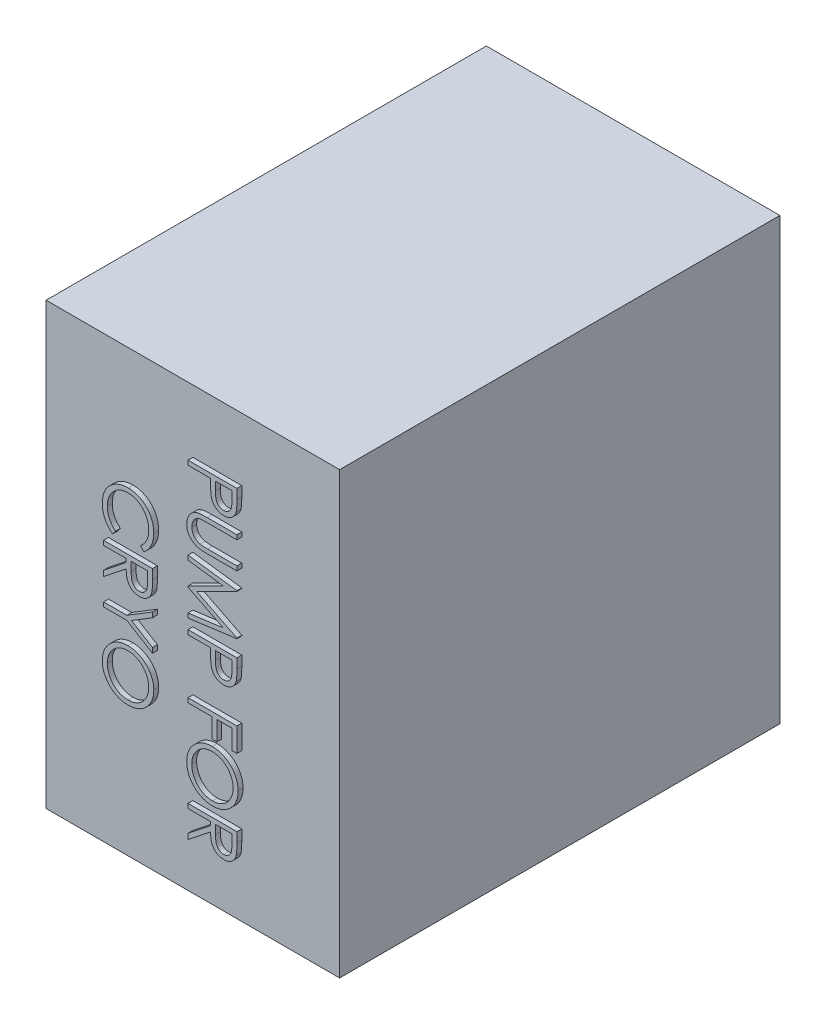
from build123d import *

# Parameters (mm, degrees)
SKETCH1_W           = 300
SKETCH1_H           = 450
BOSS_EXTRUDE1_DEPTH = 450
BOSS_EXTRUDE2_DEPTH = 5


with BuildPart() as part:
    # Sketch1 → Boss-Extrude1 (new body)
    with BuildSketch(Plane.XY):
        with Locations((-150, -225)):
            Rectangle(SKETCH1_W, SKETCH1_H)
    extrude(amount=BOSS_EXTRUDE1_DEPTH)

    # Sketch2 → Boss-Extrude2 (add)
    with BuildSketch(Plane.XY.offset(450)):
        with BuildLine():
            Line((-100, -64.102564103), (-100, -73.908253205))
            add(Edge.make_bspline(
                [(-100, -73.908253205), (-100.000741375, -74.582694722), (-100.002161882, -75.874954619), (-100.04522968, -77.728026843), (-100.102753852, -79.411023009), (-100.182495184, -80.920314165), (-100.276732187, -82.260544138), (-100.408904178, -83.425648417), (-100.5469084, -84.424784936), (-100.687214208, -85.0234485), (-100.751201923, -85.296474359)],
                knots=[0, 0, 0, 0, 0.002023262, 0.00387666, 0.005560425, 0.007074966, 0.008410857, 0.009589944, 0.010592848, 0.011433717, 0.011433717, 0.011433717, 0.011433717], degree=3))
            add(Edge.make_bspline(
                [(-100.751201923, -85.296474359), (-100.845800362, -85.642097086), (-101.032768147, -86.325198373), (-101.407262122, -87.309487184), (-101.851247723, -88.246014513), (-102.357471585, -89.137731916), (-102.946645825, -89.97464631), (-103.600133174, -90.76747075), (-104.317574111, -91.520752651), (-105.112876751, -92.208903257), (-105.956718523, -92.842434238), (-106.867892244, -93.385907714), (-107.826566564, -93.845614526), (-108.842559481, -94.221054979), (-109.909696057, -94.506534547), (-111.031091598, -94.717455866), (-112.202892896, -94.852405942), (-113.003765212, -94.86525428), (-113.411458333, -94.871794872)],
                knots=[0, 0, 0, 0, 0.001074519, 0.002123719, 0.003154202, 0.004181614, 0.005195808, 0.006220482, 0.007261811, 0.008312396, 0.009372109, 0.010423362, 0.011489587, 0.012557551, 0.01366793, 0.014799431, 0.015978517, 0.017201129, 0.017201129, 0.017201129, 0.017201129], degree=3))
            add(Edge.make_bspline(
                [(-113.411458333, -94.871794872), (-113.82256943, -94.865774519), (-114.626936058, -94.853995291), (-115.803690175, -94.712619786), (-116.928238606, -94.522188477), (-117.998087898, -94.229373444), (-119.006884619, -93.845863828), (-119.970045076, -93.395977359), (-120.871183246, -92.853355497), (-121.71357064, -92.229857929), (-122.497997959, -91.536263724), (-123.218780737, -90.775507464), (-123.871699857, -89.950660429), (-124.458219053, -89.064344028), (-124.964737331, -88.107917616), (-125.418413116, -87.09588685), (-125.799428268, -86.019455187), (-125.999857717, -85.27456213), (-126.101762821, -84.895833333)],
                knots=[0, 0, 0, 0, 0.001232622, 0.002411709, 0.003551249, 0.004651965, 0.005732814, 0.006785688, 0.007836942, 0.008882645, 0.009925708, 0.010974286, 0.012022337, 0.013077971, 0.014157938, 0.015265423, 0.016402716, 0.017579034, 0.017579034, 0.017579034, 0.017579034], degree=3))
            add(Edge.make_bspline(
                [(-126.101762821, -84.895833333), (-126.168376836, -84.582585705), (-126.314365324, -83.896085314), (-126.477343279, -82.765474997), (-126.61645186, -81.449112341), (-126.720753825, -79.948794057), (-126.810044803, -78.265866843), (-126.881017573, -76.39942031), (-126.920015485, -74.345790636), (-126.922026811, -72.913344292), (-126.923076923, -72.165464744)],
                knots=[0, 0, 0, 0, 0.000960547, 0.002105094, 0.003424665, 0.004931103, 0.006616208, 0.008480508, 0.010534184, 0.012777796, 0.012777796, 0.012777796, 0.012777796], degree=3))
            Line((-126.923076923, -72.165464744), (-126.923076923, -68.58974359))
            Line((-126.923076923, -68.58974359), (-150, -68.58974359))
            Line((-150, -68.58974359), (-150, -64.102564103))
            Line((-150, -64.102564103), (-100, -64.102564103))
        make_face()
        with BuildLine():
            Line((-105.128205128, -68.58974359), (-121.794871795, -68.58974359))
            Line((-121.794871795, -68.58974359), (-121.905048077, -77.34375))
            add(Edge.make_bspline(
                [(-121.905048077, -77.34375), (-121.90531537, -77.771181692), (-121.905831375, -78.59632976), (-121.848118443, -79.791548756), (-121.784457215, -80.897591588), (-121.684760991, -81.916860184), (-121.553401851, -82.841565239), (-121.410419938, -83.683584272), (-121.216707899, -84.430590566), (-120.946607266, -85.30594516), (-120.494923622, -86.278046537), (-119.822399654, -87.328568408), (-118.988684457, -88.233281863), (-118.038418974, -89.010951), (-116.977443965, -89.613642521), (-115.851169479, -90.066943386), (-114.658886826, -90.330988536), (-113.843404018, -90.366618241), (-113.431490385, -90.384615385)],
                knots=[0, 0, 0, 0, 0.00128209, 0.002475049, 0.003589036, 0.004605601, 0.005546148, 0.006390945, 0.007165878, 0.007859591, 0.009136978, 0.010367687, 0.011587176, 0.012812002, 0.01403695, 0.01523289, 0.016443131, 0.017678396, 0.017678396, 0.017678396, 0.017678396], degree=3))
            add(Edge.make_bspline(
                [(-113.431490385, -90.384615385), (-113.029542859, -90.366522138), (-112.230520924, -90.330555002), (-111.058934898, -90.064860623), (-109.944609761, -89.614527409), (-108.896696682, -89.006867071), (-107.95032017, -88.251527291), (-107.135420641, -87.366863135), (-106.471420622, -86.37093885), (-106.045803633, -85.444036191), (-105.785501602, -84.621235176), (-105.603452769, -83.906475179), (-105.458080533, -83.099471151), (-105.340375336, -82.199929713), (-105.239610992, -81.21483262), (-105.171240074, -80.135713674), (-105.131219215, -78.966661676), (-105.129234148, -78.155082085), (-105.128205128, -77.734375)],
                knots=[0, 0, 0, 0, 0.001205299, 0.002395985, 0.00358262, 0.004798897, 0.00601744, 0.007201239, 0.008392978, 0.009594108, 0.010246612, 0.010980247, 0.011805339, 0.012704832, 0.013701464, 0.01477547, 0.015948029, 0.017210088, 0.017210088, 0.017210088, 0.017210088], degree=3))
            Line((-105.128205128, -77.734375), (-105.128205128, -68.58974359))
        make_face(mode=Mode.SUBTRACT)
        with BuildLine():
            Line((-100, -105.128205128), (-100, -109.615384615))
            Line((-100, -109.615384615), (-129.957932692, -109.615384615))
            add(Edge.make_bspline(
                [(-129.957932692, -109.615384615), (-130.381943203, -109.614716844), (-131.186576217, -109.613449634), (-132.331837653, -109.621914118), (-133.350015639, -109.645619381), (-134.24503489, -109.660564517), (-135.012788425, -109.693812139), (-135.657435721, -109.720927095), (-136.175924327, -109.755792191), (-136.478508985, -109.797693869), (-136.608573718, -109.815705128)],
                knots=[0, 0, 0, 0, 0.001272035, 0.002413906, 0.003435737, 0.004327388, 0.005099208, 0.005740937, 0.006263309, 0.006657131, 0.006657131, 0.006657131, 0.006657131], degree=3))
            add(Edge.make_bspline(
                [(-136.608573718, -109.815705128), (-137.077853835, -109.889597031), (-137.989971814, -110.033217292), (-139.288105566, -110.400576311), (-140.462049998, -110.9094937), (-141.535217976, -111.529128951), (-142.491654872, -112.325994653), (-143.379616216, -113.274423282), (-144.146751983, -114.434228671), (-144.85251309, -115.72302087), (-145.41894825, -117.112989734), (-145.847479077, -118.533104043), (-146.108592437, -119.962301318), (-146.138830514, -120.919102122), (-146.153846154, -121.394230769)],
                knots=[0, 0, 0, 0, 0.001424425, 0.002768589, 0.004033784, 0.005255124, 0.006472184, 0.007755057, 0.009138574, 0.010630995, 0.01215807, 0.013631652, 0.015075801, 0.016500332, 0.016500332, 0.016500332, 0.016500332], degree=3))
            add(Edge.make_bspline(
                [(-146.153846154, -121.394230769), (-146.138506283, -121.802142086), (-146.107915142, -122.615608732), (-145.918453499, -123.824261007), (-145.577065053, -125.001447487), (-145.136314149, -126.152726129), (-144.554883314, -127.232617266), (-143.878583124, -128.240348071), (-143.096878169, -129.149367994), (-142.219448029, -129.969133937), (-141.238481753, -130.686877446), (-140.156934972, -131.292467329), (-138.978363059, -131.80286353), (-138.147300372, -132.052990737), (-137.720352564, -132.181490385)],
                knots=[0, 0, 0, 0, 0.001223965, 0.00244086, 0.003658457, 0.004895345, 0.00613203, 0.007329353, 0.008529815, 0.009720417, 0.010924424, 0.012166775, 0.01343197, 0.01476865, 0.01476865, 0.01476865, 0.01476865], degree=3))
            add(Edge.make_bspline(
                [(-137.720352564, -132.181490385), (-137.543944359, -132.224349317), (-137.150835787, -132.319856292), (-136.486245922, -132.409099792), (-135.702112151, -132.502050155), (-134.792800539, -132.566544012), (-133.761358073, -132.629418589), (-132.602411538, -132.667033915), (-131.32016924, -132.684420099), (-130.425352644, -132.689601247), (-129.957932692, -132.692307692)],
                knots=[0, 0, 0, 0, 0.000544286, 0.001212889, 0.002009273, 0.002913438, 0.003946837, 0.005109387, 0.006391594, 0.007793874, 0.007793874, 0.007793874, 0.007793874], degree=3))
            Line((-129.957932692, -132.692307692), (-100, -132.692307692))
            Line((-100, -132.692307692), (-100, -137.179487179))
            Line((-100, -137.179487179), (-130.198317308, -137.179487179))
            add(Edge.make_bspline(
                [(-130.198317308, -137.179487179), (-130.74258572, -137.175896994), (-131.804758618, -137.16889053), (-133.361125254, -137.106896573), (-134.837883804, -137.010907692), (-136.233150012, -136.865793325), (-137.548585435, -136.705592285), (-138.782268237, -136.476377019), (-139.942470557, -136.236758088), (-141.027205972, -135.933667699), (-142.050826631, -135.56804074), (-143.040331391, -135.139960867), (-143.987631414, -134.616144321), (-144.906408203, -134.018398024), (-145.797920455, -133.354736354), (-146.641231847, -132.589785227), (-147.463990341, -131.76314859), (-148.239046249, -130.857413643), (-148.954892577, -129.888766889), (-149.570663595, -128.855487692), (-150.111345813, -127.77838221), (-150.538432516, -126.645913735), (-150.868999438, -125.465458545), (-151.112273458, -124.237077647), (-151.251058756, -122.956593758), (-151.271632859, -122.085659644), (-151.282051282, -121.64463141)],
                knots=[0, 0, 0, 0, 0.001632735, 0.003186382, 0.004672133, 0.006071405, 0.007394506, 0.008646029, 0.009834564, 0.010947606, 0.012021565, 0.013093467, 0.014178207, 0.015264473, 0.01638026, 0.017508164, 0.018676781, 0.019877243, 0.021081251, 0.022285384, 0.023481366, 0.024692353, 0.025909949, 0.027155324, 0.028445021, 0.029768085, 0.029768085, 0.029768085, 0.029768085], degree=3))
            add(Edge.make_bspline(
                [(-151.282051282, -121.64463141), (-151.27084035, -121.16364423), (-151.248844541, -120.219949103), (-151.122805253, -118.829405285), (-150.88539962, -117.496345338), (-150.58311471, -116.206689952), (-150.166204177, -114.977997136), (-149.679088108, -113.793805073), (-149.080841532, -112.674395343), (-148.415221632, -111.601607791), (-147.666298229, -110.604111275), (-146.85001003, -109.688434087), (-145.97943321, -108.853064507), (-145.045142271, -108.112083131), (-144.054403599, -107.453213351), (-143.004414459, -106.885638874), (-141.895581371, -106.398306815), (-141.124821365, -106.146784429), (-140.735176282, -106.01963141)],
                knots=[0, 0, 0, 0, 0.001443177, 0.002831508, 0.004183412, 0.005502526, 0.006801138, 0.008071634, 0.009339562, 0.010604043, 0.011856046, 0.013076276, 0.014280617, 0.015471008, 0.016648861, 0.017845514, 0.019047604, 0.020276599, 0.020276599, 0.020276599, 0.020276599], degree=3))
            add(Edge.make_bspline(
                [(-140.735176282, -106.01963141), (-140.468996647, -105.945672008), (-139.891647091, -105.785252417), (-138.936125826, -105.61346245), (-137.835912716, -105.469046998), (-136.590932454, -105.333253309), (-135.200220074, -105.253125339), (-133.664378419, -105.182876214), (-131.981550395, -105.127710232), (-130.809343029, -105.128035552), (-130.198317308, -105.128205128)],
                knots=[0, 0, 0, 0, 0.000828429, 0.001796881, 0.00290884, 0.004157634, 0.005552777, 0.007086832, 0.008770269, 0.010603229, 0.010603229, 0.010603229, 0.010603229], degree=3))
            Line((-130.198317308, -105.128205128), (-100, -105.128205128))
        make_face()
        Polygon((-150, -148.076923077), (-100, -154.677483974), (-100, -155.318509615), (-141.025641026, -175.961538462), (-100, -196.554487179), (-100, -197.205528846), (-150, -203.846153846), (-150, -199.338942308), (-114.022435897, -194.551282051), (-150, -176.502403846), (-150, -175.490785256), (-113.942307692, -157.371794872), (-150, -152.594150641), align=None)
        with BuildLine():
            Line((-100, -214.102564103), (-100, -223.908253205))
            add(Edge.make_bspline(
                [(-100, -223.908253205), (-100.000741375, -224.582694722), (-100.002161882, -225.874954619), (-100.04522968, -227.728026843), (-100.102753852, -229.411023009), (-100.182495184, -230.920314165), (-100.276732187, -232.260544138), (-100.408904178, -233.425648417), (-100.5469084, -234.424784936), (-100.687214208, -235.0234485), (-100.751201923, -235.296474359)],
                knots=[0, 0, 0, 0, 0.002023262, 0.00387666, 0.005560425, 0.007074966, 0.008410857, 0.009589944, 0.010592848, 0.011433717, 0.011433717, 0.011433717, 0.011433717], degree=3))
            add(Edge.make_bspline(
                [(-100.751201923, -235.296474359), (-100.845800362, -235.642097086), (-101.032768147, -236.325198373), (-101.407262122, -237.309487184), (-101.851247723, -238.246014513), (-102.357471585, -239.137731916), (-102.946645825, -239.97464631), (-103.600133174, -240.76747075), (-104.317574111, -241.520752651), (-105.112876751, -242.208903257), (-105.956718523, -242.842434238), (-106.867892244, -243.385907714), (-107.826566564, -243.845614526), (-108.842559481, -244.221054979), (-109.909696057, -244.506534547), (-111.031091598, -244.717455866), (-112.202892896, -244.852405942), (-113.003765212, -244.86525428), (-113.411458333, -244.871794872)],
                knots=[0, 0, 0, 0, 0.001074519, 0.002123719, 0.003154202, 0.004181614, 0.005195808, 0.006220482, 0.007261811, 0.008312396, 0.009372109, 0.010423362, 0.011489587, 0.012557551, 0.01366793, 0.014799431, 0.015978517, 0.017201129, 0.017201129, 0.017201129, 0.017201129], degree=3))
            add(Edge.make_bspline(
                [(-113.411458333, -244.871794872), (-113.82256943, -244.865774519), (-114.626936058, -244.853995291), (-115.803690175, -244.712619786), (-116.928238606, -244.522188477), (-117.998087898, -244.229373444), (-119.006884619, -243.845863828), (-119.970045076, -243.395977359), (-120.871183246, -242.853355497), (-121.71357064, -242.229857929), (-122.497997959, -241.536263724), (-123.218780737, -240.775507464), (-123.871699857, -239.950660429), (-124.458219053, -239.064344028), (-124.964737331, -238.107917616), (-125.418413116, -237.09588685), (-125.799428268, -236.019455187), (-125.999857717, -235.27456213), (-126.101762821, -234.895833333)],
                knots=[0, 0, 0, 0, 0.001232622, 0.002411709, 0.003551249, 0.004651965, 0.005732814, 0.006785688, 0.007836942, 0.008882645, 0.009925708, 0.010974286, 0.012022337, 0.013077971, 0.014157938, 0.015265423, 0.016402716, 0.017579034, 0.017579034, 0.017579034, 0.017579034], degree=3))
            add(Edge.make_bspline(
                [(-126.101762821, -234.895833333), (-126.168376836, -234.582585705), (-126.314365324, -233.896085314), (-126.477343279, -232.765474997), (-126.61645186, -231.449112341), (-126.720753825, -229.948794057), (-126.810044803, -228.265866843), (-126.881017573, -226.39942031), (-126.920015485, -224.345790636), (-126.922026811, -222.913344292), (-126.923076923, -222.165464744)],
                knots=[0, 0, 0, 0, 0.000960547, 0.002105094, 0.003424665, 0.004931103, 0.006616208, 0.008480508, 0.010534184, 0.012777796, 0.012777796, 0.012777796, 0.012777796], degree=3))
            Line((-126.923076923, -222.165464744), (-126.923076923, -218.58974359))
            Line((-126.923076923, -218.58974359), (-150, -218.58974359))
            Line((-150, -218.58974359), (-150, -214.102564103))
            Line((-150, -214.102564103), (-100, -214.102564103))
        make_face()
        with BuildLine():
            Line((-105.128205128, -218.58974359), (-121.794871795, -218.58974359))
            Line((-121.794871795, -218.58974359), (-121.905048077, -227.34375))
            add(Edge.make_bspline(
                [(-121.905048077, -227.34375), (-121.90531537, -227.771181692), (-121.905831375, -228.59632976), (-121.848118443, -229.791548756), (-121.784457215, -230.897591588), (-121.684760991, -231.916860184), (-121.553401851, -232.841565239), (-121.410419938, -233.683584272), (-121.216707899, -234.430590566), (-120.946607266, -235.30594516), (-120.494923622, -236.278046537), (-119.822399654, -237.328568408), (-118.988684457, -238.233281863), (-118.038418974, -239.010951), (-116.977443965, -239.613642521), (-115.851169479, -240.066943386), (-114.658886826, -240.330988536), (-113.843404018, -240.366618241), (-113.431490385, -240.384615385)],
                knots=[0, 0, 0, 0, 0.00128209, 0.002475049, 0.003589036, 0.004605601, 0.005546148, 0.006390945, 0.007165878, 0.007859591, 0.009136978, 0.010367687, 0.011587176, 0.012812002, 0.01403695, 0.01523289, 0.016443131, 0.017678396, 0.017678396, 0.017678396, 0.017678396], degree=3))
            add(Edge.make_bspline(
                [(-113.431490385, -240.384615385), (-113.029542859, -240.366522138), (-112.230520924, -240.330555002), (-111.058934898, -240.064860623), (-109.944609761, -239.614527409), (-108.896696682, -239.006867071), (-107.95032017, -238.251527291), (-107.135420641, -237.366863135), (-106.471420622, -236.37093885), (-106.045803633, -235.444036191), (-105.785501602, -234.621235176), (-105.603452769, -233.906475179), (-105.458080533, -233.099471151), (-105.340375336, -232.199929713), (-105.239610992, -231.21483262), (-105.171240074, -230.135713674), (-105.131219215, -228.966661676), (-105.129234148, -228.155082085), (-105.128205128, -227.734375)],
                knots=[0, 0, 0, 0, 0.001205299, 0.002395985, 0.00358262, 0.004798897, 0.00601744, 0.007201239, 0.008392978, 0.009594108, 0.010246612, 0.010980247, 0.011805339, 0.012704832, 0.013701464, 0.01477547, 0.015948029, 0.017210088, 0.017210088, 0.017210088, 0.017210088], degree=3))
            Line((-105.128205128, -227.734375), (-105.128205128, -218.58974359))
        make_face(mode=Mode.SUBTRACT)
        Polygon((-100, -274.358974359), (-100, -298.717948718), (-105.128205128, -298.717948718), (-105.128205128, -278.846153846), (-120.512820513, -278.846153846), (-120.512820513, -298.717948718), (-125.641025641, -298.717948718), (-125.641025641, -278.846153846), (-150, -278.846153846), (-150, -274.358974359), align=None)
        with BuildLine():
            add(Edge.make_bspline(
                [(-98.717948718, -331.08974359), (-98.741398637, -332.015573488), (-98.787456212, -333.833979793), (-99.140011798, -336.506480979), (-99.749957065, -339.057829786), (-100.562244803, -341.508867143), (-101.646028776, -343.830064723), (-102.955254722, -346.039681527), (-104.508542919, -348.131470126), (-106.279829906, -350.086256754), (-108.214087517, -351.868505037), (-110.284239677, -353.425643084), (-112.461938884, -354.742191539), (-114.754762956, -355.821273995), (-117.15262036, -356.668589888), (-119.669144872, -357.253095055), (-122.287801283, -357.626511573), (-124.073900808, -357.670163557), (-124.979967949, -357.692307692)],
                knots=[0, 0, 0, 0, 0.002777041, 0.005454338, 0.008068425, 0.01063716, 0.01318702, 0.015737884, 0.018330081, 0.020989388, 0.023640628, 0.026208738, 0.028747558, 0.031261122, 0.033798499, 0.036361545, 0.039000478, 0.041717481, 0.041717481, 0.041717481, 0.041717481], degree=3))
            add(Edge.make_bspline(
                [(-124.979967949, -357.692307692), (-125.879360815, -357.67016684), (-127.65216835, -357.626524655), (-130.254206432, -357.252670054), (-132.755542924, -356.666424838), (-135.151759294, -355.829133917), (-137.446284297, -354.755235379), (-139.627986339, -353.429788976), (-141.71247244, -351.882960188), (-143.65611999, -350.106872088), (-145.441869477, -348.173075748), (-147.001428456, -346.097085909), (-148.334186754, -343.92152988), (-149.405867874, -341.630091865), (-150.259180439, -339.248317597), (-150.841516307, -336.754378207), (-151.217003142, -334.159401877), (-151.260130639, -332.389819632), (-151.282051282, -331.490384615)],
                knots=[0, 0, 0, 0, 0.00269699, 0.005316081, 0.007869381, 0.010393996, 0.012916623, 0.015455444, 0.018039598, 0.020691481, 0.023342722, 0.025924856, 0.028468867, 0.030982431, 0.033500919, 0.036044476, 0.038653646, 0.041350637, 0.041350637, 0.041350637, 0.041350637], degree=3))
            add(Edge.make_bspline(
                [(-151.282051282, -331.490384615), (-151.259920154, -330.584321144), (-151.216293811, -328.798228853), (-150.84223115, -326.176296608), (-150.257511571, -323.657949966), (-149.421091115, -321.25094288), (-148.344185353, -318.95448547), (-147.020828098, -316.768799838), (-145.461433324, -314.691259538), (-143.687709859, -312.743005951), (-141.752984156, -310.962565541), (-139.690639895, -309.396565391), (-137.520291153, -308.08083757), (-135.250884518, -307.003477198), (-132.888286014, -306.151326164), (-130.417634013, -305.569774909), (-127.852772934, -305.193561631), (-126.106447325, -305.150204675), (-125.220352564, -305.128205128)],
                knots=[0, 0, 0, 0, 0.002717003, 0.005355936, 0.007928729, 0.010462803, 0.01298543, 0.015524251, 0.018114396, 0.020766279, 0.023417519, 0.025991657, 0.028521909, 0.031017367, 0.033516982, 0.03604106, 0.038620474, 0.041277441, 0.041277441, 0.041277441, 0.041277441], degree=3))
            add(Edge.make_bspline(
                [(-125.220352564, -305.128205128), (-124.62559743, -305.135835775), (-123.443590263, -305.151000804), (-121.688393113, -305.333842313), (-119.96123382, -305.598623271), (-118.267918257, -305.980080845), (-116.608169911, -306.472128756), (-114.985383059, -307.078494334), (-113.386190706, -307.773389519), (-111.841028318, -308.600758224), (-110.347470654, -309.503442243), (-108.924193409, -310.48772847), (-107.596620159, -311.560479805), (-106.34341893, -312.70637225), (-105.185979018, -313.941267523), (-104.099065565, -315.246580488), (-103.093929901, -316.629141135), (-102.191682641, -318.091136019), (-101.362957572, -319.595291025), (-100.671040337, -321.15251887), (-100.059478292, -322.729963614), (-99.573467819, -324.341520008), (-99.186697788, -325.983460256), (-98.923897327, -327.657836963), (-98.740649548, -329.362925542), (-98.725548218, -330.511661036), (-98.717948718, -331.08974359)],
                knots=[0, 0, 0, 0, 0.001783556, 0.003544611, 0.005288464, 0.007023435, 0.008747414, 0.010477724, 0.012217776, 0.013974126, 0.015731389, 0.01745126, 0.019160982, 0.02084808, 0.022541499, 0.024234297, 0.025941258, 0.027664393, 0.02938543, 0.031088891, 0.032772328, 0.03445794, 0.03613433, 0.037828727, 0.039539944, 0.04127344, 0.04127344, 0.04127344, 0.04127344], degree=3))
        make_face()
        with BuildLine():
            add(Edge.make_bspline(
                [(-103.846153846, -331.310096154), (-103.851935239, -330.835600306), (-103.863442755, -329.891144823), (-104.015136546, -328.487096032), (-104.231124526, -327.101436685), (-104.540003892, -325.734242175), (-104.956979832, -324.392869906), (-105.448297028, -323.063924458), (-106.026257254, -321.753786957), (-106.700173268, -320.477103808), (-107.436353327, -319.236008988), (-108.244336454, -318.056865649), (-109.120204789, -316.951436543), (-110.052388692, -315.916180582), (-111.050372774, -314.954114485), (-112.098229133, -314.045736518), (-113.226122884, -313.227606401), (-114.403411821, -312.477810621), (-115.628577959, -311.806841963), (-116.888718664, -311.210193907), (-118.194114239, -310.722136674), (-119.530602191, -310.324102717), (-120.896065904, -309.994105422), (-122.300863744, -309.785049363), (-123.737936773, -309.631729942), (-124.709106116, -309.620875007), (-125.200320513, -309.615384615)],
                knots=[0, 0, 0, 0, 0.00142284, 0.002832077, 0.004231743, 0.005628862, 0.007032428, 0.008442697, 0.009877648, 0.011324713, 0.012771049, 0.014204601, 0.015609311, 0.016999266, 0.018380498, 0.019765646, 0.021155962, 0.02255638, 0.02395048, 0.025344004, 0.026735511, 0.028126585, 0.029525964, 0.030945416, 0.032384555, 0.033857456, 0.033857456, 0.033857456, 0.033857456], degree=3))
            add(Edge.make_bspline(
                [(-125.200320513, -309.615384615), (-125.922637953, -309.633596929), (-127.343659814, -309.669426184), (-129.426061869, -309.983105757), (-131.427323103, -310.466276821), (-133.336493235, -311.178524913), (-135.16998299, -312.069247979), (-136.911527343, -313.169632126), (-138.561596977, -314.473333349), (-140.108672248, -315.954240871), (-141.520755165, -317.57313668), (-142.760232432, -319.292175679), (-143.808950286, -321.0929415), (-144.663308463, -322.98013011), (-145.340304718, -324.943666382), (-145.804285162, -326.996202826), (-146.10964881, -329.124066534), (-146.138973895, -330.574504465), (-146.153846154, -331.310096154)],
                knots=[0, 0, 0, 0, 0.002165779, 0.004260757, 0.006303756, 0.008331847, 0.01036105, 0.012409076, 0.014498972, 0.016659673, 0.018824919, 0.020934713, 0.023008224, 0.025065634, 0.027140306, 0.029227344, 0.031370516, 0.033575884, 0.033575884, 0.033575884, 0.033575884], degree=3))
            add(Edge.make_bspline(
                [(-146.153846154, -331.310096154), (-146.147053254, -331.80451762), (-146.133580895, -332.785103881), (-145.997885217, -334.243611137), (-145.780288185, -335.675843509), (-145.466989035, -337.079787499), (-145.074901137, -338.45386683), (-144.609020408, -339.803753129), (-144.028071398, -341.11530587), (-143.385161717, -342.404171606), (-142.657512246, -343.638096962), (-141.860823106, -344.808792294), (-141.000618715, -345.909470602), (-140.076529761, -346.942515888), (-139.096522143, -347.911248029), (-138.035398248, -348.78936188), (-136.92414777, -349.617293064), (-135.744112804, -350.364086578), (-134.51636489, -351.033721235), (-133.251450935, -351.616010093), (-131.953718013, -352.110312084), (-130.620966636, -352.509271392), (-129.255815608, -352.821926066), (-127.856413418, -353.037352076), (-126.425565958, -353.188044439), (-125.457796547, -353.199402633), (-124.969951923, -353.205128205)],
                knots=[0, 0, 0, 0, 0.001482913, 0.002941062, 0.004390205, 0.005826413, 0.007253126, 0.008675437, 0.010106362, 0.011553184, 0.012994413, 0.014400122, 0.01579864, 0.017181904, 0.018555963, 0.019928158, 0.021310406, 0.022710824, 0.024113711, 0.025503017, 0.026885156, 0.028276231, 0.029673349, 0.031082907, 0.032522047, 0.033984935, 0.033984935, 0.033984935, 0.033984935], degree=3))
            add(Edge.make_bspline(
                [(-124.969951923, -353.205128205), (-124.485444719, -353.19939802), (-123.524335431, -353.188031141), (-122.103466597, -353.037424361), (-120.714135005, -352.821697356), (-119.361794962, -352.510801527), (-118.046101747, -352.110085045), (-116.768291065, -351.615980325), (-115.523602564, -351.03333319), (-114.315112608, -350.36464427), (-113.155473491, -349.612989649), (-112.046867607, -348.791643314), (-111.010114124, -347.886424065), (-110.019618631, -346.923195099), (-109.096505404, -345.877896885), (-108.240471371, -344.755263547), (-107.430845636, -343.568927449), (-106.700509314, -342.31281583), (-106.025912272, -341.016504543), (-105.448438563, -339.686191306), (-104.954854961, -338.33461596), (-104.541710655, -336.96869851), (-104.230821909, -335.578816614), (-104.015214039, -334.173064145), (-103.863426512, -332.749038308), (-103.851929672, -331.791265622), (-103.846153846, -331.310096154)],
                knots=[0, 0, 0, 0, 0.001452876, 0.002882048, 0.004281713, 0.005669068, 0.007040971, 0.008404402, 0.009775537, 0.011160866, 0.01254442, 0.013918625, 0.015296183, 0.016670242, 0.018060991, 0.019475345, 0.020903252, 0.022366826, 0.023831668, 0.025284958, 0.026714024, 0.028146351, 0.029563008, 0.03098246, 0.032411631, 0.033854495, 0.033854495, 0.033854495, 0.033854495], degree=3))
        make_face(mode=Mode.SUBTRACT)
        with BuildLine():
            Line((-100, -367.948717949), (-100, -377.954727564))
            add(Edge.make_bspline(
                [(-100, -377.954727564), (-100.002222657, -378.622457971), (-100.006490405, -379.90457432), (-100.030287018, -381.741335325), (-100.098492099, -383.410293854), (-100.157186149, -384.910577273), (-100.264213882, -386.242158058), (-100.366508841, -387.409119354), (-100.500418281, -388.406086462), (-100.624781466, -389.009598623), (-100.681089744, -389.282852564)],
                knots=[0, 0, 0, 0, 0.00200323, 0.003846424, 0.00551017, 0.007014209, 0.0083501, 0.009517171, 0.010528542, 0.011365345, 0.011365345, 0.011365345, 0.011365345], degree=3))
            add(Edge.make_bspline(
                [(-100.681089744, -389.282852564), (-100.771461853, -389.648667924), (-100.950278188, -390.372494808), (-101.328421238, -391.41454513), (-101.765295649, -392.407951778), (-102.282403622, -393.348986789), (-102.870725679, -394.237737459), (-103.53369917, -395.072873087), (-104.274700369, -395.849618965), (-105.074807223, -396.573951773), (-105.941000907, -397.230536153), (-106.860663324, -397.798724026), (-107.828042525, -398.285260449), (-108.846507281, -398.673677108), (-109.907448149, -398.986146402), (-111.020129139, -399.206541428), (-112.179576093, -399.338695673), (-112.970402747, -399.352151522), (-113.371394231, -399.358974359)],
                knots=[0, 0, 0, 0, 0.001129726, 0.002235352, 0.003320462, 0.004382822, 0.005452335, 0.006514459, 0.007577197, 0.008669357, 0.009749092, 0.010833092, 0.011908125, 0.012992542, 0.014098712, 0.015222294, 0.016391426, 0.017594017, 0.017594017, 0.017594017, 0.017594017], degree=3))
            add(Edge.make_bspline(
                [(-113.371394231, -399.358974359), (-114.037610778, -399.337989216), (-115.337571815, -399.297041768), (-117.224145126, -398.915246965), (-118.984031637, -398.289895931), (-120.614782196, -397.428032168), (-122.085468199, -396.330990398), (-123.372850655, -395.012595654), (-124.460103794, -393.479580885), (-125.206055276, -392.04574439), (-125.686032431, -390.778567477), (-126.025441464, -389.732286478), (-126.283255417, -388.590104134), (-126.517572278, -387.368406787), (-126.696374867, -386.057757924), (-126.823358688, -384.660796869), (-126.905010251, -383.174029742), (-126.916939894, -382.154890289), (-126.923076923, -381.630608974)],
                knots=[0, 0, 0, 0, 0.00199681, 0.003896293, 0.005746413, 0.007583473, 0.009408398, 0.011228698, 0.013088149, 0.015027873, 0.016058356, 0.017151205, 0.01832462, 0.019568101, 0.020882606, 0.022290882, 0.023775418, 0.025348221, 0.025348221, 0.025348221, 0.025348221], degree=3))
            Line((-126.923076923, -381.630608974), (-150, -400))
            Line((-150, -400), (-150, -394.451121795))
            Line((-150, -394.451121795), (-126.923076923, -376.081730769))
            Line((-126.923076923, -376.081730769), (-126.923076923, -372.435897436))
            Line((-126.923076923, -372.435897436), (-150, -372.435897436))
            Line((-150, -372.435897436), (-150, -367.948717949))
            Line((-150, -367.948717949), (-100, -367.948717949))
        make_face()
        with BuildLine():
            Line((-105.128205128, -372.435897436), (-121.794871795, -372.435897436))
            Line((-121.794871795, -372.435897436), (-121.864983974, -381.590544872))
            add(Edge.make_bspline(
                [(-121.864983974, -381.590544872), (-121.865173068, -382.017973997), (-121.865539585, -382.846453381), (-121.808485658, -384.045034331), (-121.743581048, -385.161035845), (-121.644304894, -386.190189721), (-121.516360322, -387.132954185), (-121.35631994, -387.988863015), (-121.169854569, -388.759297075), (-120.881290812, -389.65788781), (-120.423853112, -390.660995175), (-119.759450917, -391.752510078), (-118.918370558, -392.678869697), (-117.971893909, -393.477571236), (-116.909859812, -394.092774843), (-115.779407957, -394.540535134), (-114.590297907, -394.821529667), (-113.77355728, -394.854935947), (-113.361378205, -394.871794872)],
                knots=[0, 0, 0, 0, 0.00128209, 0.002485056, 0.003599044, 0.004635545, 0.005586013, 0.006452327, 0.007246693, 0.007962541, 0.009280552, 0.010545033, 0.011779404, 0.013016941, 0.014246916, 0.015442856, 0.016655292, 0.017890556, 0.017890556, 0.017890556, 0.017890556], degree=3))
            add(Edge.make_bspline(
                [(-113.361378205, -394.871794872), (-112.959172788, -394.854884124), (-112.162148414, -394.821373192), (-110.998527893, -394.539990697), (-109.892429872, -394.085599106), (-108.864937316, -393.448436935), (-107.924480288, -392.678524176), (-107.13092433, -391.764138292), (-106.466367466, -390.751328878), (-106.044793987, -389.804039988), (-105.785814707, -388.957923473), (-105.603798076, -388.223179094), (-105.45632881, -387.389825237), (-105.341674243, -386.45985907), (-105.238498234, -385.434963057), (-105.171601642, -384.312330834), (-105.131169331, -383.093258794), (-105.12921619, -382.248299048), (-105.128205128, -381.810897436)],
                knots=[0, 0, 0, 0, 0.001205299, 0.002388462, 0.003569589, 0.004778918, 0.00600235, 0.007201808, 0.008396406, 0.009624911, 0.010296508, 0.011049577, 0.011894374, 0.012833587, 0.01386012, 0.014984103, 0.016206715, 0.017518853, 0.017518853, 0.017518853, 0.017518853], degree=3))
            Line((-105.128205128, -381.810897436), (-105.128205128, -372.435897436))
        make_face(mode=Mode.SUBTRACT)
        with BuildLine():
            Line((-195.431089744, -167.948717949), (-198.435897436, -164.022435897))
            add(Edge.make_bspline(
                [(-198.435897436, -164.022435897), (-198.102097867, -163.742351778), (-197.438999071, -163.185959681), (-196.507862721, -162.290828216), (-195.635501844, -161.357947603), (-194.817760706, -160.387674443), (-194.083235481, -159.362544165), (-193.393648296, -158.307389898), (-192.775537754, -157.204560681), (-192.026066524, -155.6795359), (-191.243978595, -153.684566639), (-190.588218148, -151.173211795), (-190.170772781, -148.551624674), (-190.125560761, -146.763087536), (-190.102564103, -145.853365385)],
                knots=[0, 0, 0, 0, 0.001306928, 0.002596236, 0.003871776, 0.005137526, 0.006399704, 0.007652669, 0.008917388, 0.010189541, 0.012748886, 0.015328999, 0.017963804, 0.020691273, 0.020691273, 0.020691273, 0.020691273], degree=3))
            add(Edge.make_bspline(
                [(-190.102564103, -145.853365385), (-190.108361035, -145.352181486), (-190.119901099, -144.354465149), (-190.271075741, -142.873682763), (-190.486000546, -141.417746578), (-190.797148824, -139.992070704), (-191.202235654, -138.599485887), (-191.677294377, -137.229388745), (-192.268456748, -135.897915366), (-192.921316662, -134.589041812), (-193.658928382, -133.335110978), (-194.463217869, -132.148425589), (-195.326291137, -131.034407048), (-196.245920339, -129.989968383), (-197.233534614, -129.026564119), (-198.27751585, -128.128754268), (-199.39042966, -127.312719478), (-200.551404281, -126.558407116), (-201.76214612, -125.887204025), (-203.015038602, -125.307587658), (-204.305291465, -124.810808239), (-205.635547875, -124.414074653), (-207.00057295, -124.101146089), (-208.403263581, -123.884960817), (-209.840897071, -123.735146129), (-210.815314529, -123.723712222), (-211.306490385, -123.717948718)],
                knots=[0, 0, 0, 0, 0.001502938, 0.002991927, 0.004460872, 0.005916646, 0.007365373, 0.008809905, 0.010263195, 0.011732413, 0.013195987, 0.014623895, 0.016030317, 0.017421067, 0.018795125, 0.020166151, 0.021548399, 0.022931952, 0.024317281, 0.025697495, 0.027070276, 0.02846135, 0.029858469, 0.031268026, 0.032717134, 0.034190035, 0.034190035, 0.034190035, 0.034190035], degree=3))
            add(Edge.make_bspline(
                [(-211.306490385, -123.717948718), (-212.045509241, -123.735974704), (-213.496474739, -123.771366337), (-215.621769175, -124.086342538), (-217.6577788, -124.564986699), (-219.591776548, -125.282352084), (-221.447610234, -126.166909949), (-223.193879568, -127.28463297), (-224.856973347, -128.579154933), (-226.397586886, -130.068789497), (-227.804925819, -131.703158296), (-229.044219841, -133.456699891), (-230.07728959, -135.325046859), (-230.936945969, -137.287570147), (-231.597756364, -139.359371775), (-232.062958129, -141.536726095), (-232.366417851, -143.814897456), (-232.395470537, -145.371603168), (-232.41025641, -146.163862179)],
                knots=[0, 0, 0, 0, 0.002215807, 0.004350442, 0.006432355, 0.008479254, 0.010526472, 0.012588314, 0.014686091, 0.01683956, 0.019005825, 0.021148272, 0.023269069, 0.025399683, 0.027566295, 0.029780381, 0.032072497, 0.034448006, 0.034448006, 0.034448006, 0.034448006], degree=3))
            add(Edge.make_bspline(
                [(-232.41025641, -146.163862179), (-232.386130985, -147.036757737), (-232.338646378, -148.754825007), (-231.93637139, -151.27436824), (-231.284115421, -153.686307749), (-230.371287959, -155.990773271), (-229.184640989, -158.181268217), (-227.746099883, -160.261220507), (-226.041980844, -162.2323858), (-224.740793297, -163.417689832), (-224.076923077, -164.022435897)],
                knots=[0, 0, 0, 0, 0.002617423, 0.005151715, 0.007632497, 0.01010063, 0.0125699, 0.015089841, 0.017674403, 0.020366646, 0.020366646, 0.020366646, 0.020366646], degree=3))
            Line((-224.076923077, -164.022435897), (-227.051682692, -167.948717949))
            add(Edge.make_bspline(
                [(-227.051682692, -167.948717949), (-227.459375559, -167.63274537), (-228.272808468, -167.002313703), (-229.419536843, -165.981478668), (-230.498204532, -164.906111944), (-231.499884036, -163.768086767), (-232.445486456, -162.581013928), (-233.303311223, -161.32398373), (-234.099489054, -160.01870753), (-234.818866693, -158.657585814), (-235.463867689, -157.245087325), (-236.008395364, -155.782682025), (-236.484210986, -154.282759496), (-236.873071254, -152.744564365), (-237.177067229, -151.16295795), (-237.380171578, -149.543366776), (-237.519350926, -147.88237206), (-237.532034188, -146.761779851), (-237.538461538, -146.193910256)],
                knots=[0, 0, 0, 0, 0.001547046, 0.003086683, 0.004602316, 0.006113674, 0.007632581, 0.00915228, 0.010675934, 0.012217231, 0.013768163, 0.015330824, 0.016895697, 0.018486859, 0.020087826, 0.021723998, 0.023381764, 0.02508496, 0.02508496, 0.02508496, 0.02508496], degree=3))
            add(Edge.make_bspline(
                [(-237.538461538, -146.193910256), (-237.534718788, -145.656143584), (-237.527317961, -144.592776583), (-237.407429856, -143.022794417), (-237.243862185, -141.494371834), (-236.997574599, -140.011877179), (-236.706941169, -138.567220392), (-236.317351789, -137.173497757), (-235.880935123, -135.816994752), (-235.368006741, -134.503161313), (-234.789204134, -133.230879888), (-234.135039007, -132.004254011), (-233.411012369, -130.823847834), (-232.633083648, -129.678056107), (-231.77626505, -128.583804912), (-230.852455986, -127.531611693), (-229.864770118, -126.515576318), (-229.152557927, -125.886966532), (-228.794471154, -125.570913462)],
                knots=[0, 0, 0, 0, 0.00161286, 0.003189231, 0.004721159, 0.006222895, 0.00769617, 0.009139486, 0.010561656, 0.011969683, 0.013368094, 0.014752662, 0.016137194, 0.017520712, 0.018905171, 0.020303439, 0.021719989, 0.023152386, 0.023152386, 0.023152386, 0.023152386], degree=3))
            add(Edge.make_bspline(
                [(-228.794471154, -125.570913462), (-228.172454169, -125.064689983), (-226.935929735, -124.0583546), (-224.931844288, -122.770844835), (-222.839441304, -121.668736903), (-220.647728036, -120.777652321), (-218.361622504, -120.081041847), (-215.979972298, -119.598453346), (-213.505001695, -119.284858996), (-211.821619, -119.248997728), (-210.965945513, -119.230769231)],
                knots=[0, 0, 0, 0, 0.002404368, 0.004779708, 0.007131768, 0.009490218, 0.011866572, 0.014290574, 0.016772771, 0.019338829, 0.019338829, 0.019338829, 0.019338829], degree=3))
            add(Edge.make_bspline(
                [(-210.965945513, -119.230769231), (-210.066619518, -119.253085652), (-208.297251769, -119.296991819), (-205.699943961, -119.666942038), (-203.215120141, -120.269292463), (-200.833219296, -121.098733012), (-198.56786976, -122.192986864), (-196.409504005, -123.517669647), (-194.359884398, -125.085720311), (-192.445215519, -126.877445636), (-190.694699978, -128.842796818), (-189.154599159, -130.947324233), (-187.872923574, -133.18707347), (-186.801548962, -135.537326579), (-185.978056866, -138.015693979), (-185.401582706, -140.616884823), (-185.042766777, -143.336012216), (-184.997406662, -145.19118972), (-184.974358974, -146.133814103)],
                knots=[0, 0, 0, 0, 0.00269699, 0.00530616, 0.007852064, 0.010357772, 0.012857548, 0.015384467, 0.017942655, 0.020585994, 0.02323939, 0.025827811, 0.028394494, 0.030967502, 0.033564725, 0.036213353, 0.03895024, 0.041777316, 0.041777316, 0.041777316, 0.041777316], degree=3))
            add(Edge.make_bspline(
                [(-184.974358974, -146.133814103), (-184.981241516, -146.708307685), (-184.994864814, -147.845459874), (-185.127884309, -149.527624307), (-185.34923296, -151.16543182), (-185.652495578, -152.762843225), (-186.024193888, -154.325651063), (-186.5107757, -155.837822096), (-187.07581647, -157.307590661), (-187.70999369, -158.736057534), (-188.435003556, -160.107681425), (-189.222440269, -161.42221272), (-190.090480501, -162.663794002), (-191.010426816, -163.8557795), (-192.016691247, -164.971333846), (-193.076504012, -166.042316997), (-194.221313467, -167.03173316), (-195.027092796, -167.642496821), (-195.431089744, -167.948717949)],
                knots=[0, 0, 0, 0, 0.001723222, 0.003410945, 0.00505836, 0.006679008, 0.008287196, 0.009874191, 0.01144041, 0.013009606, 0.014559761, 0.016091984, 0.017603442, 0.019102102, 0.020605974, 0.022107443, 0.02361973, 0.025140353, 0.025140353, 0.025140353, 0.025140353], degree=3))
        make_face()
        with BuildLine():
            Line((-186.256410256, -178.205128205), (-186.256410256, -188.211137821))
            add(Edge.make_bspline(
                [(-186.256410256, -188.211137821), (-186.258632913, -188.878868228), (-186.262900661, -190.160984577), (-186.286697274, -191.997745582), (-186.354902355, -193.66670411), (-186.413596405, -195.166987529), (-186.520624138, -196.498568314), (-186.622919097, -197.665529611), (-186.756828537, -198.662496718), (-186.881191722, -199.266008879), (-186.9375, -199.539262821)],
                knots=[0, 0, 0, 0, 0.00200323, 0.003846424, 0.00551017, 0.007014209, 0.0083501, 0.009517171, 0.010528542, 0.011365345, 0.011365345, 0.011365345, 0.011365345], degree=3))
            add(Edge.make_bspline(
                [(-186.9375, -199.539262821), (-187.027872109, -199.90507818), (-187.206688445, -200.628905065), (-187.584831494, -201.670955386), (-188.021705906, -202.664362034), (-188.538813878, -203.605397045), (-189.127135935, -204.494147715), (-189.790109426, -205.329283343), (-190.531110626, -206.106029221), (-191.331217479, -206.830362029), (-192.197411163, -207.486946409), (-193.11707358, -208.055134282), (-194.084452781, -208.541670706), (-195.102917538, -208.930087365), (-196.163858405, -209.242556658), (-197.276539396, -209.462951685), (-198.43598635, -209.59510593), (-199.226813003, -209.608561779), (-199.627804487, -209.615384615)],
                knots=[0, 0, 0, 0, 0.001129726, 0.002235352, 0.003320462, 0.004382822, 0.005452335, 0.006514459, 0.007577197, 0.008669357, 0.009749092, 0.010833092, 0.011908125, 0.012992542, 0.014098712, 0.015222294, 0.016391426, 0.017594017, 0.017594017, 0.017594017, 0.017594017], degree=3))
            add(Edge.make_bspline(
                [(-199.627804487, -209.615384615), (-200.294021034, -209.594399473), (-201.593982071, -209.553452024), (-203.480555383, -209.171657221), (-205.240441894, -208.546306187), (-206.871192452, -207.684442424), (-208.341878455, -206.587400655), (-209.629260911, -205.26900591), (-210.716514051, -203.735991141), (-211.462465532, -202.302154646), (-211.942442687, -201.034977733), (-212.28185172, -199.988696734), (-212.539665674, -198.846514391), (-212.773982534, -197.624817044), (-212.952785124, -196.31416818), (-213.079768944, -194.917207126), (-213.161420507, -193.430439998), (-213.17335015, -192.411300546), (-213.179487179, -191.887019231)],
                knots=[0, 0, 0, 0, 0.00199681, 0.003896293, 0.005746413, 0.007583473, 0.009408398, 0.011228698, 0.013088149, 0.015027873, 0.016058356, 0.017151205, 0.01832462, 0.019568101, 0.020882606, 0.022290882, 0.023775418, 0.025348221, 0.025348221, 0.025348221, 0.025348221], degree=3))
            Line((-213.179487179, -191.887019231), (-236.256410256, -210.256410256))
            Line((-236.256410256, -210.256410256), (-236.256410256, -204.707532051))
            Line((-236.256410256, -204.707532051), (-213.179487179, -186.338141026))
            Line((-213.179487179, -186.338141026), (-213.179487179, -182.692307692))
            Line((-213.179487179, -182.692307692), (-236.256410256, -182.692307692))
            Line((-236.256410256, -182.692307692), (-236.256410256, -178.205128205))
            Line((-236.256410256, -178.205128205), (-186.256410256, -178.205128205))
        make_face()
        with BuildLine():
            Line((-191.384615385, -182.692307692), (-208.051282051, -182.692307692))
            Line((-208.051282051, -182.692307692), (-208.121394231, -191.846955128))
            add(Edge.make_bspline(
                [(-208.121394231, -191.846955128), (-208.121583324, -192.274384254), (-208.121949842, -193.102863638), (-208.064895914, -194.301444588), (-207.999991305, -195.417446102), (-207.90071515, -196.446599977), (-207.772770578, -197.389364441), (-207.612730197, -198.245273272), (-207.426264825, -199.015707331), (-207.137701068, -199.914298066), (-206.680263369, -200.917405432), (-206.015861174, -202.008920334), (-205.174780814, -202.935279953), (-204.228304166, -203.733981493), (-203.166270068, -204.3491851), (-202.035818213, -204.796945391), (-200.846708163, -205.077939924), (-200.029967536, -205.111346203), (-199.617788462, -205.128205128)],
                knots=[0, 0, 0, 0, 0.00128209, 0.002485056, 0.003599044, 0.004635545, 0.005586013, 0.006452327, 0.007246693, 0.007962541, 0.009280552, 0.010545033, 0.011779404, 0.013016941, 0.014246916, 0.015442856, 0.016655292, 0.017890556, 0.017890556, 0.017890556, 0.017890556], degree=3))
            add(Edge.make_bspline(
                [(-199.617788462, -205.128205128), (-199.215583045, -205.11129438), (-198.41855867, -205.077783449), (-197.25493815, -204.796400953), (-196.148840128, -204.342009363), (-195.121347572, -203.704847192), (-194.180890545, -202.934934433), (-193.387334586, -202.020548549), (-192.722777723, -201.007739134), (-192.301204243, -200.060450245), (-192.042224963, -199.214333729), (-191.860208332, -198.47958935), (-191.712739067, -197.646235493), (-191.598084499, -196.716269327), (-191.49490849, -195.691373313), (-191.428011899, -194.56874109), (-191.387579588, -193.34966905), (-191.385626447, -192.504709305), (-191.384615385, -192.067307692)],
                knots=[0, 0, 0, 0, 0.001205299, 0.002388462, 0.003569589, 0.004778918, 0.00600235, 0.007201808, 0.008396406, 0.009624911, 0.010296508, 0.011049577, 0.011894374, 0.012833587, 0.01386012, 0.014984103, 0.016206715, 0.017518853, 0.017518853, 0.017518853, 0.017518853], degree=3))
            Line((-191.384615385, -192.067307692), (-191.384615385, -182.692307692))
        make_face(mode=Mode.SUBTRACT)
        Polygon((-186.256410256, -216.666666667), (-186.256410256, -221.804887821), (-207.740785256, -234.945913462), (-186.256410256, -248.066907051), (-186.256410256, -253.205128205), (-212.48838141, -237.179487179), (-236.256410256, -237.179487179), (-236.256410256, -232.692307692), (-212.48838141, -232.692307692), align=None)
        with BuildLine():
            add(Edge.make_bspline(
                [(-184.974358974, -284.935897436), (-184.997808893, -285.861727334), (-185.043866469, -287.680133639), (-185.396422054, -290.352634825), (-186.006367322, -292.903983632), (-186.81865506, -295.355020989), (-187.902439033, -297.676218569), (-189.211664979, -299.885835373), (-190.764953175, -301.977623972), (-192.536240163, -303.9324106), (-194.470497774, -305.714658883), (-196.540649934, -307.27179693), (-198.71834914, -308.588345385), (-201.011173213, -309.667427841), (-203.409030616, -310.514743734), (-205.925555128, -311.099248902), (-208.544211539, -311.472665419), (-210.330311064, -311.516317403), (-211.236378205, -311.538461538)],
                knots=[0, 0, 0, 0, 0.002777041, 0.005454338, 0.008068425, 0.01063716, 0.01318702, 0.015737884, 0.018330081, 0.020989388, 0.023640628, 0.026208738, 0.028747558, 0.031261122, 0.033798499, 0.036361545, 0.039000478, 0.041717481, 0.041717481, 0.041717481, 0.041717481], degree=3))
            add(Edge.make_bspline(
                [(-211.236378205, -311.538461538), (-212.135771072, -311.516320686), (-213.908578607, -311.472678501), (-216.510616689, -311.0988239), (-219.011953181, -310.512578684), (-221.40816955, -309.675287763), (-223.702694553, -308.601389225), (-225.884396596, -307.275942822), (-227.968882696, -305.729114034), (-229.912530246, -303.953025934), (-231.698279733, -302.019229594), (-233.257838713, -299.943239756), (-234.59059701, -297.767683726), (-235.66227813, -295.476245711), (-236.515590696, -293.094471443), (-237.097926563, -290.600532053), (-237.473413399, -288.005555723), (-237.516540895, -286.235973478), (-237.538461538, -285.336538462)],
                knots=[0, 0, 0, 0, 0.00269699, 0.005316081, 0.007869381, 0.010393996, 0.012916623, 0.015455444, 0.018039598, 0.020691481, 0.023342722, 0.025924856, 0.028468867, 0.030982431, 0.033500919, 0.036044476, 0.038653646, 0.041350637, 0.041350637, 0.041350637, 0.041350637], degree=3))
            add(Edge.make_bspline(
                [(-237.538461538, -285.336538462), (-237.516330411, -284.43047499), (-237.472704067, -282.644382699), (-237.098641406, -280.022450454), (-236.513921827, -277.504103812), (-235.677501372, -275.097096727), (-234.60059561, -272.800639317), (-233.277238354, -270.614953684), (-231.71784358, -268.537413384), (-229.944120115, -266.589159797), (-228.009394412, -264.808719387), (-225.947050152, -263.242719237), (-223.776701409, -261.926991416), (-221.507294774, -260.849631044), (-219.14469627, -259.997480011), (-216.674044269, -259.415928755), (-214.10918319, -259.039715477), (-212.362857582, -258.996358521), (-211.476762821, -258.974358974)],
                knots=[0, 0, 0, 0, 0.002717003, 0.005355936, 0.007928729, 0.010462803, 0.01298543, 0.015524251, 0.018114396, 0.020766279, 0.023417519, 0.025991657, 0.028521909, 0.031017367, 0.033516982, 0.03604106, 0.038620474, 0.041277441, 0.041277441, 0.041277441, 0.041277441], degree=3))
            add(Edge.make_bspline(
                [(-211.476762821, -258.974358974), (-210.882007686, -258.981989621), (-209.700000519, -258.99715465), (-207.944803369, -259.17999616), (-206.217644076, -259.444777117), (-204.524328514, -259.826234691), (-202.864580167, -260.318282602), (-201.241793315, -260.92464818), (-199.642600962, -261.619543365), (-198.097438574, -262.44691207), (-196.60388091, -263.349596089), (-195.180603666, -264.333882316), (-193.853030415, -265.406633652), (-192.599829187, -266.552526096), (-191.442389274, -267.787421369), (-190.355475822, -269.092734334), (-189.350340157, -270.475294982), (-188.448092897, -271.937289865), (-187.619367828, -273.441444871), (-186.927450593, -274.998672716), (-186.315888548, -276.57611746), (-185.829878075, -278.187673854), (-185.443108044, -279.829614102), (-185.180307583, -281.503990809), (-184.997059804, -283.209079388), (-184.981958474, -284.357814882), (-184.974358974, -284.935897436)],
                knots=[0, 0, 0, 0, 0.001783556, 0.003544611, 0.005288464, 0.007023435, 0.008747414, 0.010477724, 0.012217776, 0.013974126, 0.015731389, 0.01745126, 0.019160982, 0.02084808, 0.022541499, 0.024234297, 0.025941258, 0.027664393, 0.02938543, 0.031088891, 0.032772328, 0.03445794, 0.03613433, 0.037828727, 0.039539944, 0.04127344, 0.04127344, 0.04127344, 0.04127344], degree=3))
        make_face()
        with BuildLine():
            add(Edge.make_bspline(
                [(-190.102564103, -285.15625), (-190.108345496, -284.681754152), (-190.119853011, -283.737298669), (-190.271546802, -282.333249878), (-190.487534782, -280.947590531), (-190.796414149, -279.580396021), (-191.213390088, -278.239023752), (-191.704707284, -276.910078304), (-192.282667511, -275.599940803), (-192.956583525, -274.323257654), (-193.692763583, -273.082162835), (-194.500746711, -271.903019495), (-195.376615046, -270.797590389), (-196.308798948, -269.762334428), (-197.30678303, -268.800268331), (-198.354639389, -267.891890365), (-199.48253314, -267.073760248), (-200.659822078, -266.323964467), (-201.884988216, -265.652995809), (-203.14512892, -265.056347754), (-204.450524495, -264.56829052), (-205.787012447, -264.170256564), (-207.15247616, -263.840259268), (-208.557274, -263.631203209), (-209.994347029, -263.477883789), (-210.965516373, -263.467028854), (-211.456730769, -263.461538462)],
                knots=[0, 0, 0, 0, 0.00142284, 0.002832077, 0.004231743, 0.005628862, 0.007032428, 0.008442697, 0.009877648, 0.011324713, 0.012771049, 0.014204601, 0.015609311, 0.016999266, 0.018380498, 0.019765646, 0.021155962, 0.02255638, 0.02395048, 0.025344004, 0.026735511, 0.028126585, 0.029525964, 0.030945416, 0.032384555, 0.033857456, 0.033857456, 0.033857456, 0.033857456], degree=3))
            add(Edge.make_bspline(
                [(-211.456730769, -263.461538462), (-212.179048209, -263.479750775), (-213.60007007, -263.51558003), (-215.682472126, -263.829259603), (-217.683733359, -264.312430667), (-219.592903492, -265.024678759), (-221.426393247, -265.915401826), (-223.167937599, -267.015785972), (-224.818007233, -268.319487195), (-226.365082504, -269.800394718), (-227.777165422, -271.419290526), (-229.016642688, -273.138329525), (-230.065360543, -274.939095346), (-230.91971872, -276.826283957), (-231.596714974, -278.789820228), (-232.060695419, -280.842356672), (-232.366059067, -282.97022038), (-232.395384151, -284.420658311), (-232.41025641, -285.15625)],
                knots=[0, 0, 0, 0, 0.002165779, 0.004260757, 0.006303756, 0.008331847, 0.01036105, 0.012409076, 0.014498972, 0.016659673, 0.018824919, 0.020934713, 0.023008224, 0.025065634, 0.027140306, 0.029227344, 0.031370516, 0.033575884, 0.033575884, 0.033575884, 0.033575884], degree=3))
            add(Edge.make_bspline(
                [(-232.41025641, -285.15625), (-232.403463511, -285.650671466), (-232.389991151, -286.631257728), (-232.254295474, -288.089764983), (-232.036698442, -289.521997355), (-231.723399291, -290.925941345), (-231.331311394, -292.300020676), (-230.865430665, -293.649906975), (-230.284481655, -294.961459716), (-229.641571973, -296.250325452), (-228.913922502, -297.484250808), (-228.117233363, -298.65494614), (-227.257028971, -299.755624448), (-226.332940017, -300.788669734), (-225.352932399, -301.757401875), (-224.291808504, -302.635515727), (-223.180558026, -303.46344691), (-222.00052306, -304.210240424), (-220.772775147, -304.879875082), (-219.507861192, -305.462163939), (-218.210128269, -305.95646593), (-216.877376892, -306.355425238), (-215.512225864, -306.668079912), (-214.112823674, -306.883505922), (-212.681976214, -307.034198286), (-211.714206804, -307.045556479), (-211.226362179, -307.051282051)],
                knots=[0, 0, 0, 0, 0.001482913, 0.002941062, 0.004390205, 0.005826413, 0.007253126, 0.008675437, 0.010106362, 0.011553184, 0.012994413, 0.014400122, 0.01579864, 0.017181904, 0.018555963, 0.019928158, 0.021310406, 0.022710824, 0.024113711, 0.025503017, 0.026885156, 0.028276231, 0.029673349, 0.031082907, 0.032522047, 0.033984935, 0.033984935, 0.033984935, 0.033984935], degree=3))
            add(Edge.make_bspline(
                [(-211.226362179, -307.051282051), (-210.741854976, -307.045551866), (-209.780745687, -307.034184988), (-208.359876854, -306.883578207), (-206.970545261, -306.667851202), (-205.618205218, -306.356955373), (-204.302512003, -305.956238891), (-203.024701322, -305.462134171), (-201.78001282, -304.879487036), (-200.571522864, -304.210798116), (-199.411883747, -303.459143495), (-198.303277864, -302.63779716), (-197.26652438, -301.732577911), (-196.276028887, -300.769348945), (-195.352915661, -299.724050732), (-194.496881627, -298.601417393), (-193.687255892, -297.415081295), (-192.95691957, -296.158969676), (-192.282322529, -294.862658389), (-191.704848819, -293.532345152), (-191.211265217, -292.180769807), (-190.798120912, -290.814852356), (-190.487232165, -289.42497046), (-190.271624295, -288.019217991), (-190.119836769, -286.595192154), (-190.108339929, -285.637419468), (-190.102564103, -285.15625)],
                knots=[0, 0, 0, 0, 0.001452876, 0.002882048, 0.004281713, 0.005669068, 0.007040971, 0.008404402, 0.009775537, 0.011160866, 0.01254442, 0.013918625, 0.015296183, 0.016670242, 0.018060991, 0.019475345, 0.020903252, 0.022366826, 0.023831668, 0.025284958, 0.026714024, 0.028146351, 0.029563008, 0.03098246, 0.032411631, 0.033854495, 0.033854495, 0.033854495, 0.033854495], degree=3))
        make_face(mode=Mode.SUBTRACT)
    extrude(amount=BOSS_EXTRUDE2_DEPTH)


solid = part.part
